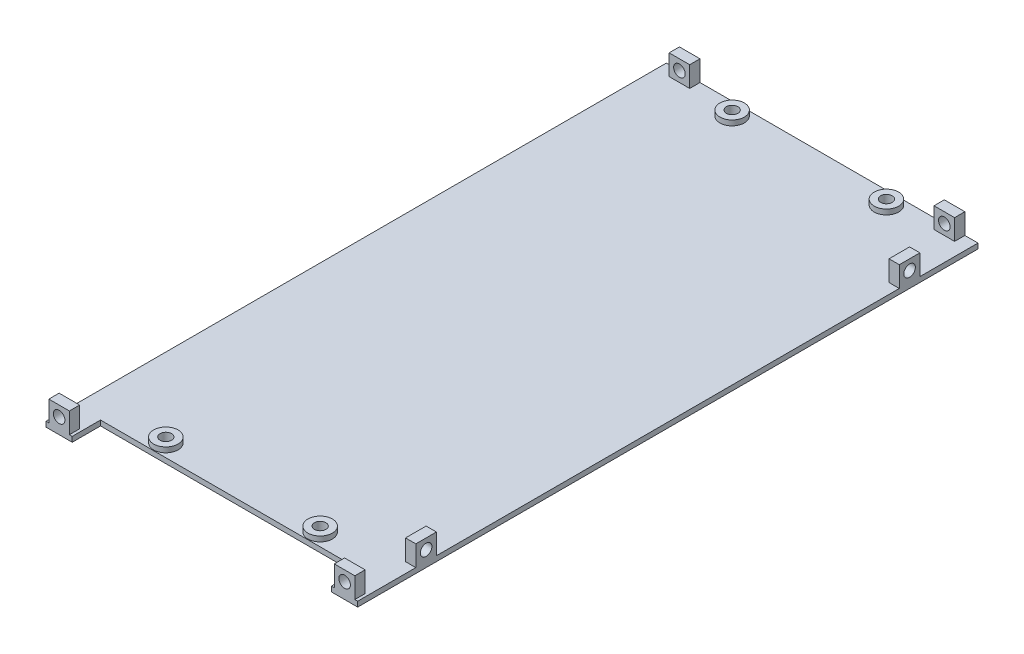
from build123d import *

# Parameters (mm, degrees)
BOSS_EXTRUDE1_DEPTH = 2
SKETCH2_W           = 8
SKETCH2_H           = 4
SKETCH2_W_2         = 4
SKETCH2_H_2         = 8
BOSS_EXTRUDE2_DEPTH = 8
CUT_EXTRUDE1_REACH  = 243.2
SKETCH3_R           = 2.25
CUT_EXTRUDE3_REACH  = 243.2
SKETCH5_R           = 2.25
CUT_EXTRUDE4_REACH  = 123.2
SKETCH6_R           = 2.25
SKETCH7_R           = 4.75
SKETCH7_R_2         = 2.25
BOSS_EXTRUDE3_DEPTH = 4
CUT_EXTRUDE5_REACH  = 6
SKETCH8_R           = 2.25


with BuildPart() as part:
    # Sketch1 → Boss-Extrude1 (new body)
    with BuildSketch(Plane(origin=(0, 0, 0), x_dir=(1, 0, 0), z_dir=(0, 1, 0))):
        Polygon((0.4, 241.6), (121.6, 241.6), (121.6, 0.4), (111.4, 0.4), (111.4, 11.4), (10.6, 11.4), (10.6, 0.4), (0.4, 0.4), align=None)
    extrude(amount=BOSS_EXTRUDE1_DEPTH)

    # Sketch2 → Boss-Extrude2 (add)
    with BuildSketch(Plane(origin=(0, 2, 0), x_dir=(1, 0, 0), z_dir=(0, 1, 0))):
        with Locations((9.5, 239.6)):
            Rectangle(SKETCH2_W, SKETCH2_H)
        with Locations((112.5, 239.6)):
            Rectangle(SKETCH2_W, SKETCH2_H)
        with Locations((5.5, 2.4)):
            Rectangle(SKETCH2_W, SKETCH2_H)
        with Locations((116.5, 2.4)):
            Rectangle(SKETCH2_W, SKETCH2_H)
        with Locations((119.6, 27)):
            Rectangle(SKETCH2_W_2, SKETCH2_H_2)
        with Locations((119.6, 215)):
            Rectangle(SKETCH2_W_2, SKETCH2_H_2)
    extrude(amount=BOSS_EXTRUDE2_DEPTH)

    # Sketch3 → Cut-Extrude1 (cut, up to next)
    with BuildSketch(Plane.XY.offset(-0.4), mode=Mode.PRIVATE) as cut_extrude1_sk1:
        with Locations((5.5, 6)):
            Circle(SKETCH3_R)
    cut_extrude1_tool1 = extrude(cut_extrude1_sk1.sketch, amount=-CUT_EXTRUDE1_REACH, mode=Mode.PRIVATE) & part.part
    add(cut_extrude1_tool1.solids().sort_by_distance((5.5, 6, -0.4))[0], mode=Mode.SUBTRACT)
    # Sketch3 → Cut-Extrude1 (cut, up to next)
    with BuildSketch(Plane.XY.offset(-0.4), mode=Mode.PRIVATE) as cut_extrude1_sk2:
        with Locations((116.5, 6)):
            Circle(SKETCH3_R)
    cut_extrude1_tool2 = extrude(cut_extrude1_sk2.sketch, amount=-CUT_EXTRUDE1_REACH, mode=Mode.PRIVATE) & part.part
    add(cut_extrude1_tool2.solids().sort_by_distance((116.5, 6, -0.4))[0], mode=Mode.SUBTRACT)

    # Sketch5 → Cut-Extrude3 (cut, up to next)
    with BuildSketch(Plane(origin=(0, 0, -241.6), x_dir=(-1, 0, 0), z_dir=(0, 0, -1)), mode=Mode.PRIVATE) as cut_extrude3_sk1:
        with Locations((-112.5, 6)):
            Circle(SKETCH5_R)
    cut_extrude3_tool1 = extrude(cut_extrude3_sk1.sketch, amount=-CUT_EXTRUDE3_REACH, mode=Mode.PRIVATE) & part.part
    add(cut_extrude3_tool1.solids().sort_by_distance((112.5, 6, -241.6))[0], mode=Mode.SUBTRACT)
    # Sketch5 → Cut-Extrude3 (cut, up to next)
    with BuildSketch(Plane(origin=(0, 0, -241.6), x_dir=(-1, 0, 0), z_dir=(0, 0, -1)), mode=Mode.PRIVATE) as cut_extrude3_sk2:
        with Locations((-9.5, 6)):
            Circle(SKETCH5_R)
    cut_extrude3_tool2 = extrude(cut_extrude3_sk2.sketch, amount=-CUT_EXTRUDE3_REACH, mode=Mode.PRIVATE) & part.part
    add(cut_extrude3_tool2.solids().sort_by_distance((9.5, 6, -241.6))[0], mode=Mode.SUBTRACT)

    # Sketch6 → Cut-Extrude4 (cut, up to next)
    with BuildSketch(Plane(origin=(121.6, 0, 0), x_dir=(0, 0, -1), z_dir=(1, 0, 0)), mode=Mode.PRIVATE) as cut_extrude4_sk1:
        with Locations((27, 6)):
            Circle(SKETCH6_R)
    cut_extrude4_tool1 = extrude(cut_extrude4_sk1.sketch, amount=-CUT_EXTRUDE4_REACH, mode=Mode.PRIVATE) & part.part
    add(cut_extrude4_tool1.solids().sort_by_distance((121.6, 6, -27))[0], mode=Mode.SUBTRACT)
    # Sketch6 → Cut-Extrude4 (cut, up to next)
    with BuildSketch(Plane(origin=(121.6, 0, 0), x_dir=(0, 0, -1), z_dir=(1, 0, 0)), mode=Mode.PRIVATE) as cut_extrude4_sk2:
        with Locations((215, 6)):
            Circle(SKETCH6_R)
    cut_extrude4_tool2 = extrude(cut_extrude4_sk2.sketch, amount=-CUT_EXTRUDE4_REACH, mode=Mode.PRIVATE) & part.part
    add(cut_extrude4_tool2.solids().sort_by_distance((121.6, 6, -215))[0], mode=Mode.SUBTRACT)

    # Sketch7 → Boss-Extrude3 (add)
    with BuildSketch(Plane.XZ):
        with Locations((31, -236.6)):
            Circle(SKETCH7_R)
        with Locations((31, -236.6)):
            Circle(SKETCH7_R_2, mode=Mode.SUBTRACT)
        with Locations((31, -16.4)):
            Circle(SKETCH7_R)
        with Locations((31, -16.4)):
            Circle(SKETCH7_R_2, mode=Mode.SUBTRACT)
        with Locations((91, -236.6)):
            Circle(SKETCH7_R)
        with Locations((91, -236.6)):
            Circle(SKETCH7_R_2, mode=Mode.SUBTRACT)
        with Locations((91, -16.4)):
            Circle(SKETCH7_R)
        with Locations((91, -16.4)):
            Circle(SKETCH7_R_2, mode=Mode.SUBTRACT)
    extrude(amount=-BOSS_EXTRUDE3_DEPTH)

    # Sketch8 → Cut-Extrude5 (cut, up to next)
    with BuildSketch(Plane(origin=(0, 4, 0), x_dir=(1, 0, 0), z_dir=(0, 1, 0)), mode=Mode.PRIVATE) as cut_extrude5_sk1:
        with Locations((31, 16.4)):
            Circle(SKETCH8_R)
    cut_extrude5_tool1 = extrude(cut_extrude5_sk1.sketch, amount=-CUT_EXTRUDE5_REACH, mode=Mode.PRIVATE) & part.part
    add(cut_extrude5_tool1.solids().sort_by_distance((31, 4, -16.4))[0], mode=Mode.SUBTRACT)
    # Sketch8 → Cut-Extrude5 (cut, up to next)
    with BuildSketch(Plane(origin=(0, 4, 0), x_dir=(1, 0, 0), z_dir=(0, 1, 0)), mode=Mode.PRIVATE) as cut_extrude5_sk2:
        with Locations((91, 16.4)):
            Circle(SKETCH8_R)
    cut_extrude5_tool2 = extrude(cut_extrude5_sk2.sketch, amount=-CUT_EXTRUDE5_REACH, mode=Mode.PRIVATE) & part.part
    add(cut_extrude5_tool2.solids().sort_by_distance((91, 4, -16.4))[0], mode=Mode.SUBTRACT)
    # Sketch8 → Cut-Extrude5 (cut, up to next)
    with BuildSketch(Plane(origin=(0, 4, 0), x_dir=(1, 0, 0), z_dir=(0, 1, 0)), mode=Mode.PRIVATE) as cut_extrude5_sk3:
        with Locations((31, 236.6)):
            Circle(SKETCH8_R)
    cut_extrude5_tool3 = extrude(cut_extrude5_sk3.sketch, amount=-CUT_EXTRUDE5_REACH, mode=Mode.PRIVATE) & part.part
    add(cut_extrude5_tool3.solids().sort_by_distance((31, 4, -236.6))[0], mode=Mode.SUBTRACT)
    # Sketch8 → Cut-Extrude5 (cut, up to next)
    with BuildSketch(Plane(origin=(0, 4, 0), x_dir=(1, 0, 0), z_dir=(0, 1, 0)), mode=Mode.PRIVATE) as cut_extrude5_sk4:
        with Locations((91, 236.6)):
            Circle(SKETCH8_R)
    cut_extrude5_tool4 = extrude(cut_extrude5_sk4.sketch, amount=-CUT_EXTRUDE5_REACH, mode=Mode.PRIVATE) & part.part
    add(cut_extrude5_tool4.solids().sort_by_distance((91, 4, -236.6))[0], mode=Mode.SUBTRACT)


solid = part.part
